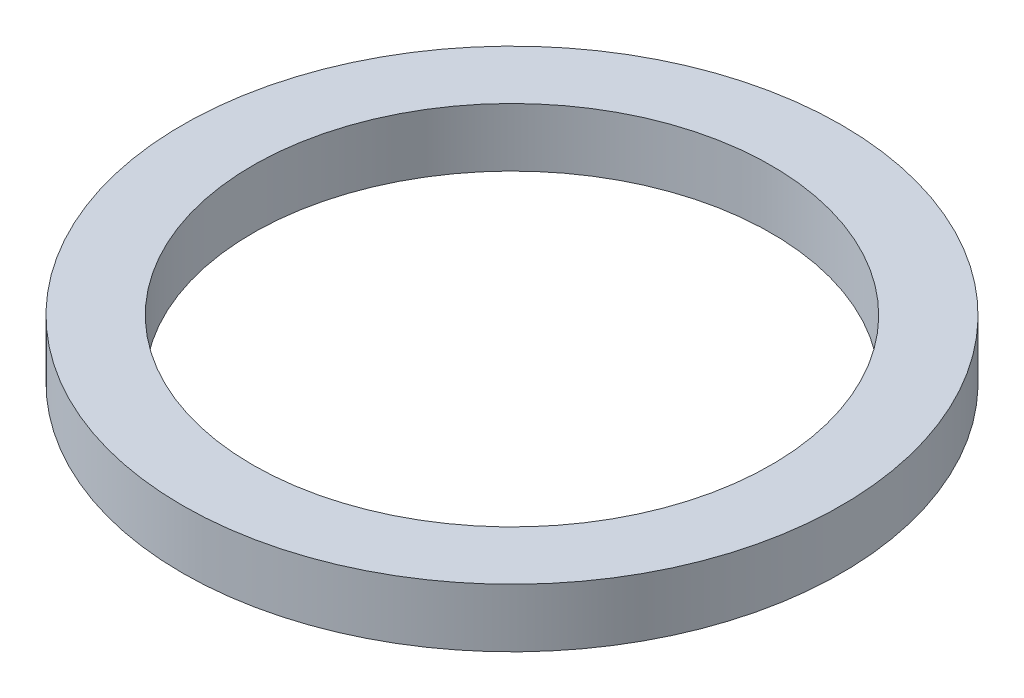
from build123d import *

# Parameters (mm, degrees)
SKETCH1_R           = 56.3
SKETCH1_R_2         = 44.3
BOSS_EXTRUDE1_DEPTH = 10


with BuildPart() as part:
    # Sketch1 → Boss-Extrude1 (new body)
    with BuildSketch(Plane(origin=(0, 0, 0), x_dir=(1, 0, 0), z_dir=(0, 1, 0))):
        Circle(SKETCH1_R)
        Circle(SKETCH1_R_2, mode=Mode.SUBTRACT)
    extrude(amount=BOSS_EXTRUDE1_DEPTH)


solid = part.part
